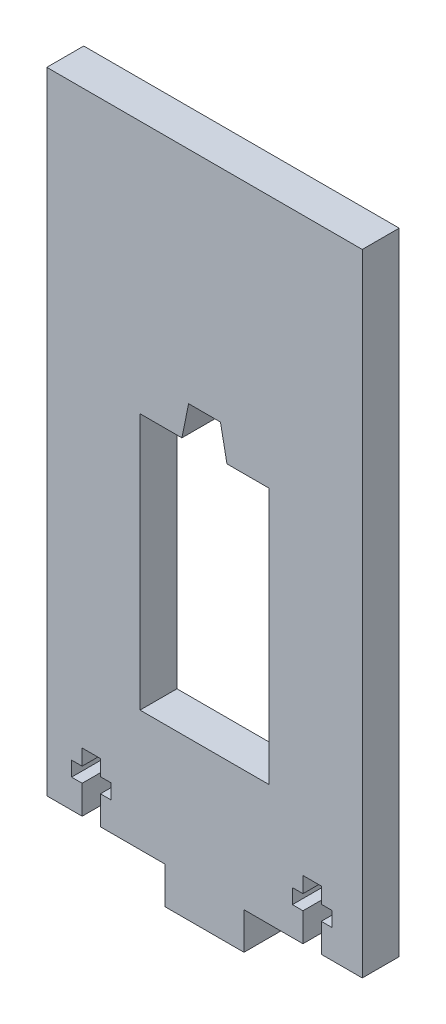
from build123d import *

# Parameters (mm, degrees)
BOSS_EXTRUDE1_DEPTH = 5.9436
CUT_EXTRUDE1_DEPTH  = 6.9436
CUT_EXTRUDE2_DEPTH  = 6.9436


with BuildPart() as part:
    # Sketch2 → Boss-Extrude1 (new body)
    with BuildSketch(Plane.XY):
        Polygon((0, 0), (0, 101.6), (-50.8, 101.6), (-50.8, 0), (-31.75, 0), (-31.75, -5.9436), (-19.05, -5.9436), (-19.05, 0), align=None)
    extrude(amount=BOSS_EXTRUDE1_DEPTH)

    # Sketch3 → Cut-Extrude1 (cut, through all)
    with BuildSketch(Plane.XY.offset(5.9436)):
        Polygon((-27.965479444, 66.110608141), (-22.834520556, 66.110608141), (-21.792739864, 60.799784967), (-15.013102806, 60.799784967), (-15.013102806, 19.467361344), (-35.786897194, 19.467361344), (-35.786897194, 60.799784967), (-29.045829513, 60.8), align=None)
    extrude(amount=-CUT_EXTRUDE1_DEPTH, mode=Mode.SUBTRACT)

    # Sketch4 → Cut-Extrude2 (cut, through all)
    with BuildSketch(Plane.XY.offset(5.9436)):
        Polygon((-9.550241905, -0.00026), (-9.550241905, 4.60375), (-11.252041905, 4.60375), (-11.252041905, 6.985), (-9.550241905, 6.985), (-9.550241905, 9.525), (-6.603841905, 9.525), (-6.603841905, 6.985), (-4.902041905, 6.985), (-4.902041905, 4.60375), (-6.603841905, 4.60375), (-6.603841905, -0.00026), align=None)
        Polygon((-46.812041905, 4.60375), (-45.110241905, 4.60375), (-45.110241905, -0.00026), (-42.163841905, -0.00026), (-42.163841905, 4.60375), (-40.462041905, 4.60375), (-40.462041905, 6.985), (-42.163841905, 6.985), (-42.163841905, 9.525), (-45.110241905, 9.525), (-45.110241905, 6.985), (-46.812041905, 6.985), align=None)
    extrude(amount=-CUT_EXTRUDE2_DEPTH, mode=Mode.SUBTRACT)


solid = part.part
